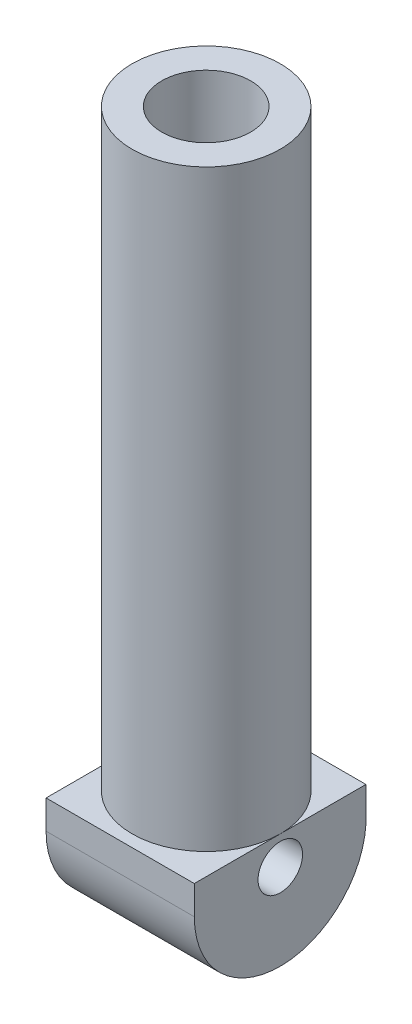
from build123d import *

# Parameters (mm, degrees)
SKETCH2_R           = 25
SKETCH2_R_2         = 15
BOSS_EXTRUDE1_DEPTH = 200
SKETCH5_R           = 7.5
BOSS_EXTRUDE2_DEPTH = 25


with BuildPart() as part:
    # Sketch2 → Boss-Extrude1 (new body)
    with BuildSketch(Plane(origin=(0, 0, 0), x_dir=(1, 0, 0), z_dir=(0, 1, 0))):
        Circle(SKETCH2_R)
        Circle(SKETCH2_R_2, mode=Mode.SUBTRACT)
    extrude(amount=BOSS_EXTRUDE1_DEPTH)

    # Sketch5 → Boss-Extrude2 (add, symmetric)
    with BuildSketch(Plane(origin=(0, 0, 0), x_dir=(0, -1, 0), z_dir=(-1, 0, 0))):
        with BuildLine():
            Line((0, 29.012112286), (9.706174679, 29.012112286))
            ThreePointArc((9.706174679, 29.012112286), (38.670140077, 0.993968953), (11.62868774, -28.883907525))
            Line((11.62868774, -28.883907525), (0, -28.883907525))
            Line((0, -28.883907525), (0, 29.012112286))
        make_face()
        with Locations((9.706174679, 0)):
            Circle(SKETCH5_R, mode=Mode.SUBTRACT)
    extrude(amount=BOSS_EXTRUDE2_DEPTH, both=True)


solid = part.part
